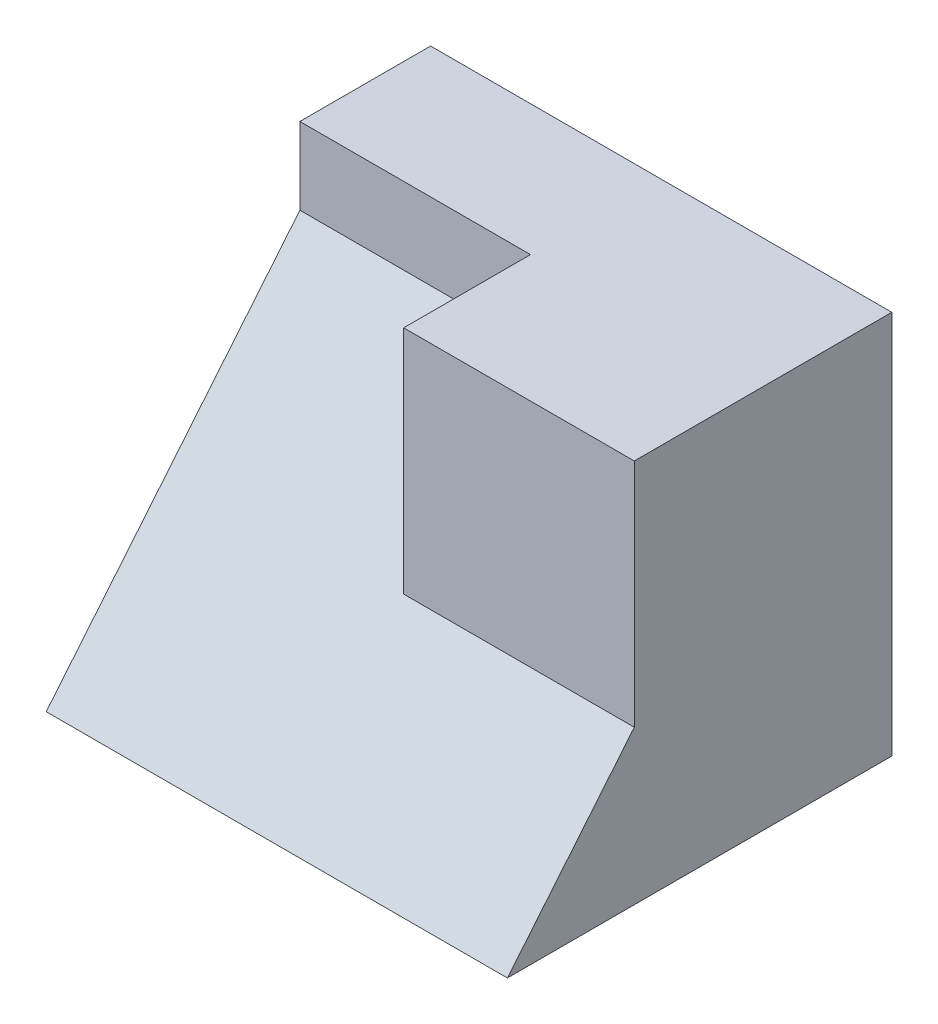
from build123d import *

# Parameters (mm, degrees)
SKETCH1_W           = 60
SKETCH1_H           = 50
BOSS_EXTRUDE1_DEPTH = 50
SKETCH2_W           = 30
SKETCH2_H           = 10
CUT_EXTRUDE1_DEPTH  = 40
SKETCH3_W           = 30
SKETCH3_H           = 30
CUT_EXTRUDE2_DEPTH  = 30
SKETCH4_W           = 30
SKETCH4_H           = 10
BOSS_EXTRUDE2_DEPTH = 7
SKETCH5_W           = 30
SKETCH5_H           = 30
BOSS_EXTRUDE3_DEPTH = 12
CUT_EXTRUDE6_DEPTH  = 10
CUT_EXTRUDE7_DEPTH  = 20
CUT_EXTRUDE8_DEPTH  = 52
SKETCH13_W          = 30
SKETCH13_H          = 30
BOSS_EXTRUDE4_DEPTH = 1.5


with BuildPart() as part:
    # Sketch1 → Boss-Extrude1 (new body)
    with BuildSketch(Plane.XY):
        with Locations((30, 25)):
            Rectangle(SKETCH1_W, SKETCH1_H)
    extrude(amount=BOSS_EXTRUDE1_DEPTH)

    # Sketch2 → Cut-Extrude1 (cut)
    with BuildSketch(Plane.XY.offset(50)):
        with Locations((15, 45)):
            Rectangle(SKETCH2_W, SKETCH2_H)
    extrude(amount=-CUT_EXTRUDE1_DEPTH, mode=Mode.SUBTRACT)

    # Sketch3 → Cut-Extrude2 (cut)
    with BuildSketch(Plane.XY.offset(50)):
        with Locations((45, 35)):
            Rectangle(SKETCH3_W, SKETCH3_H)
    extrude(amount=-CUT_EXTRUDE2_DEPTH, mode=Mode.SUBTRACT)

    # Sketch4 → Boss-Extrude2 (add)
    with BuildSketch(Plane.XY.offset(10)):
        with Locations((15, 45)):
            Rectangle(SKETCH4_W, SKETCH4_H)
    extrude(amount=BOSS_EXTRUDE2_DEPTH)

    # Sketch5 → Boss-Extrude3 (add)
    with BuildSketch(Plane.XY.offset(20)):
        with Locations((45, 35)):
            Rectangle(SKETCH5_W, SKETCH5_H)
    extrude(amount=BOSS_EXTRUDE3_DEPTH)

    # Sketch10 → Cut-Extrude6 (cut)
    with BuildSketch(Plane(origin=(0, 0, 0), x_dir=(0, 0, -1), z_dir=(1, 0, 0))):
        Polygon((-17, 40), (-50, 0), (-50, 40), align=None)
    extrude(amount=CUT_EXTRUDE6_DEPTH, mode=Mode.SUBTRACT)

    # Sketch11 → Cut-Extrude7 (cut)
    with BuildSketch(Plane.ZY.offset(-10)):
        Polygon((17, 40), (50, 40), (50, 0), align=None)
    extrude(amount=-CUT_EXTRUDE7_DEPTH, mode=Mode.SUBTRACT)

    # Sketch12 → Cut-Extrude8 (cut)
    with BuildSketch(Plane.ZY.offset(-30)):
        Polygon((33.5, 20), (50, 0), (50, 20), align=None)
    extrude(amount=-CUT_EXTRUDE8_DEPTH, mode=Mode.SUBTRACT)

    # Sketch13 → Boss-Extrude4 (add)
    with BuildSketch(Plane.XY.offset(32)):
        with Locations((45, 35)):
            Rectangle(SKETCH13_W, SKETCH13_H)
    extrude(amount=BOSS_EXTRUDE4_DEPTH)


solid = part.part
